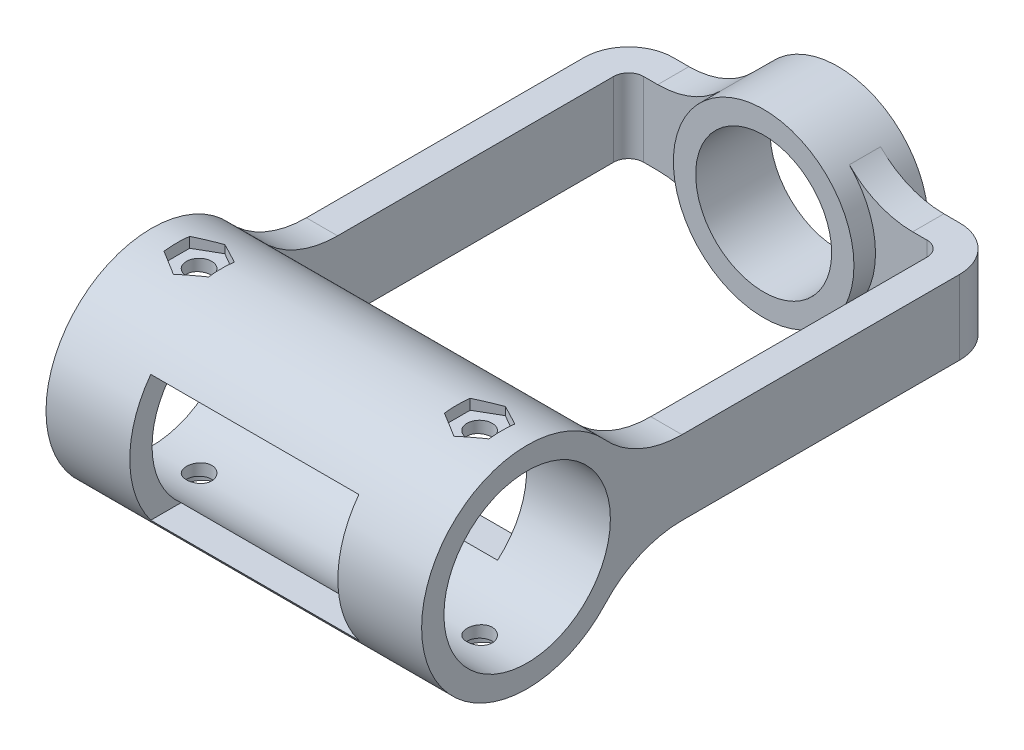
from build123d import *

# Parameters (mm, degrees)
SKETCH1_R                = 12.15
SKETCH1_R_2              = 9.15
BOSS_EXTRUDE1_DEPTH      = 10
BOSS_EXTRUDE2_DEPTH      = 2.1
BOSS_EXTRUDE2_DEPTH_BACK = 2.1
SKETCH4_W                = 4.2
SKETCH4_H                = 10
BOSS_EXTRUDE3_DEPTH      = 53
FILLET1_R                = 12
SKETCH5_R                = 14.2
SKETCH5_R_2              = 11.2
BOSS_EXTRUDE4_DEPTH      = 50.547009
BOSS_EXTRUDE11_DEPTH     = 4.2
BOSS_EXTRUDE12_DEPTH     = 4.2
FILLET2_R                = 6
FILLET3_R                = 2
SKETCH10_R               = 11.2
CUT_EXTRUDE2_DEPTH       = 51.547008827
SKETCH15_R               = 1.7
CUT_EXTRUDE5_DEPTH       = 1
CUT_EXTRUDE5_DEPTH_BACK  = 29.4
SKETCH17_R               = 2.9
CUT_EXTRUDE6_DEPTH       = 1.5
CUT_EXTRUDE7_DEPTH       = 1.5
SKETCH19_W               = 28
SKETCH19_H               = 17
CUT_EXTRUDE8_DEPTH       = 26.4000001
CUT_EXTRUDE8_DEPTH_BACK  = 4


with BuildPart() as part:
    # Sketch1 → Boss-Extrude1 (new body)
    with BuildSketch(Plane.XY):
        Circle(SKETCH1_R)
        Circle(SKETCH1_R_2, mode=Mode.SUBTRACT)
    extrude(amount=BOSS_EXTRUDE1_DEPTH)

    # Sketch2 → Boss-Extrude2 (add, two sides)
    with BuildSketch(Plane.XY.offset(5)) as boss_extrude2_sk:
        with BuildLine():
            Line((11.073504414, 5), (21.073504414, 5))
            Line((21.073504414, 5), (21.073504414, -5))
            Line((21.073504414, -5), (11.073504414, -5))
            ThreePointArc((11.073504414, -5), (12.15, 0), (11.073504414, 5))
        make_face()
        with BuildLine():
            ThreePointArc((-11.073504414, 5), (-12.15, 0), (-11.073504414, -5))
            Line((-11.073504414, -5), (-21.073504414, -5))
            Line((-21.073504414, -5), (-21.073504414, 5))
            Line((-21.073504414, 5), (-11.073504414, 5))
        make_face()
    extrude(amount=BOSS_EXTRUDE2_DEPTH)
    extrude(boss_extrude2_sk.sketch, amount=-BOSS_EXTRUDE2_DEPTH_BACK)

    # Sketch4 → Boss-Extrude3 (add)
    with BuildSketch(Plane(origin=(0, 0, 2.9), x_dir=(-1, 0, 0), z_dir=(0, 0, -1))):
        with Locations((23.173504414, 0)):
            Rectangle(SKETCH4_W, SKETCH4_H)
        with Locations((-23.173504414, 0)):
            Rectangle(SKETCH4_W, SKETCH4_H)
    extrude(amount=-BOSS_EXTRUDE3_DEPTH)

    # Fillet1
    fillet1_edges = [part.edges().sort_by_distance(p)[0] for p in [
        (11.073504414, 5, 5),
        (11.073504414, -5, 5),
        (-11.073504414, 5, 5),
        (-11.073504414, -5, 5),
    ]]
    fillet(fillet1_edges, radius=FILLET1_R)



with BuildPart() as body_2:
    # Sketch5 → Boss-Extrude4 (new body)
    with BuildSketch(Plane.ZY.offset(25.273504414)):
        with Locations((67.1, 0)):
            Circle(SKETCH5_R)
        with Locations((67.1, 0)):
            Circle(SKETCH5_R_2, mode=Mode.SUBTRACT)
    extrude(amount=-BOSS_EXTRUDE4_DEPTH)


with BuildPart() as part_1:
    add(part.part)

    add(body_2.part)  # Boss-Extrude11 merges body 2
    # Sketch7 → Boss-Extrude11 (add)
    with BuildSketch(Plane.ZY.offset(25.273504414)):
        with BuildLine():
            Line((56.60689185, -9.567375887), (56.60689185, 9.567375887))
            ThreePointArc((56.60689185, 9.567375887), (51.915920178, 6.192643958), (46.261573956, 5))
            Line((46.261573956, 5), (46.261573956, -5))
            ThreePointArc((46.261573956, -5), (51.915920178, -6.192643958), (56.60689185, -9.567375887))
        make_face()
    extrude(amount=-BOSS_EXTRUDE11_DEPTH)

    # Sketch9 → Boss-Extrude12 (add)
    with BuildSketch(Plane(origin=(25.273504414, 0, 0), x_dir=(0, 0, -1), z_dir=(1, 0, 0))):
        with BuildLine():
            Line((-56.60689185, 9.567375887), (-56.60689185, -9.567375887))
            ThreePointArc((-56.60689185, -9.567375887), (-51.915920178, -6.192643958), (-46.261573956, -5))
            Line((-46.261573956, -5), (-46.261573956, 5))
            ThreePointArc((-46.261573956, 5), (-51.915920178, 6.192643958), (-56.60689185, 9.567375887))
        make_face()
    extrude(amount=-BOSS_EXTRUDE12_DEPTH)

    # Fillet2
    fillet2_edges = [part_1.edges().sort_by_distance(p)[0] for p in [
        (-25.273504414, 0, 2.9),
        (25.273504414, 0, 2.9),
    ]]
    fillet(fillet2_edges, radius=FILLET2_R)

    # Fillet3
    fillet3_edges = [part_1.edges().sort_by_distance(p)[0] for p in [
        (21.073504414, 0, 7.1),
        (-21.073504414, 0, 7.1),
    ]]
    fillet(fillet3_edges, radius=FILLET3_R)

    # Sketch10 → Cut-Extrude2 (cut, through all)
    with BuildSketch(Plane(origin=(25.273504414, 0, 0), x_dir=(0, 0, -1), z_dir=(1, 0, 0))):
        with Locations((-67.1, 0)):
            Circle(SKETCH10_R)
    extrude(amount=-CUT_EXTRUDE2_DEPTH, mode=Mode.SUBTRACT)

    # Sketch15 → Cut-Extrude5 (cut, two sides)
    with BuildSketch(Plane(origin=(0, -14.2, 0), x_dir=(-1, 0, 0), z_dir=(0, -1, 0))) as cut_extrude5_sk:
        with Locations((-18.873504414, -67.1)):
            Circle(SKETCH15_R)
        with Locations((18.873504414, -67.1)):
            Circle(SKETCH15_R)
    extrude(amount=CUT_EXTRUDE5_DEPTH, mode=Mode.SUBTRACT)
    extrude(cut_extrude5_sk.sketch, amount=-CUT_EXTRUDE5_DEPTH_BACK, mode=Mode.SUBTRACT)

    # Sketch17 → Cut-Extrude6 (cut)
    with BuildSketch(Plane(origin=(0, -14.2, 0), x_dir=(-1, 0, 0), z_dir=(0, -1, 0))):
        with Locations((-18.873504414, -67.1)):
            Circle(SKETCH17_R)
        with Locations((18.873504414, -67.1)):
            Circle(SKETCH17_R)
    extrude(amount=-CUT_EXTRUDE6_DEPTH, mode=Mode.SUBTRACT)

    # Sketch18 → Cut-Extrude7 (cut)
    with BuildSketch(Plane(origin=(0, 14.2, 0), x_dir=(1, 0, 0), z_dir=(0, 1, 0))):
        Polygon((-15.873504414, -68.832050808), (-15.873504414, -65.367949192), (-18.873504414, -63.635898385), (-21.873504414, -65.367949192), (-21.873504414, -68.832050808), (-18.873504414, -70.564101615), align=None)
        Polygon((21.873504414, -68.832050808), (21.873504414, -65.367949192), (18.873504414, -63.635898385), (15.873504414, -65.367949192), (15.873504414, -68.832050808), (18.873504414, -70.564101615), align=None)
    extrude(amount=-CUT_EXTRUDE7_DEPTH, mode=Mode.SUBTRACT)

    # Sketch19 → Cut-Extrude8 (cut, two sides)
    with BuildSketch(Plane.XY.offset(55.9)) as cut_extrude8_sk:
        Rectangle(SKETCH19_W, SKETCH19_H)
    extrude(amount=CUT_EXTRUDE8_DEPTH, mode=Mode.SUBTRACT)
    extrude(cut_extrude8_sk.sketch, amount=-CUT_EXTRUDE8_DEPTH_BACK, mode=Mode.SUBTRACT)


solid = part_1.part
